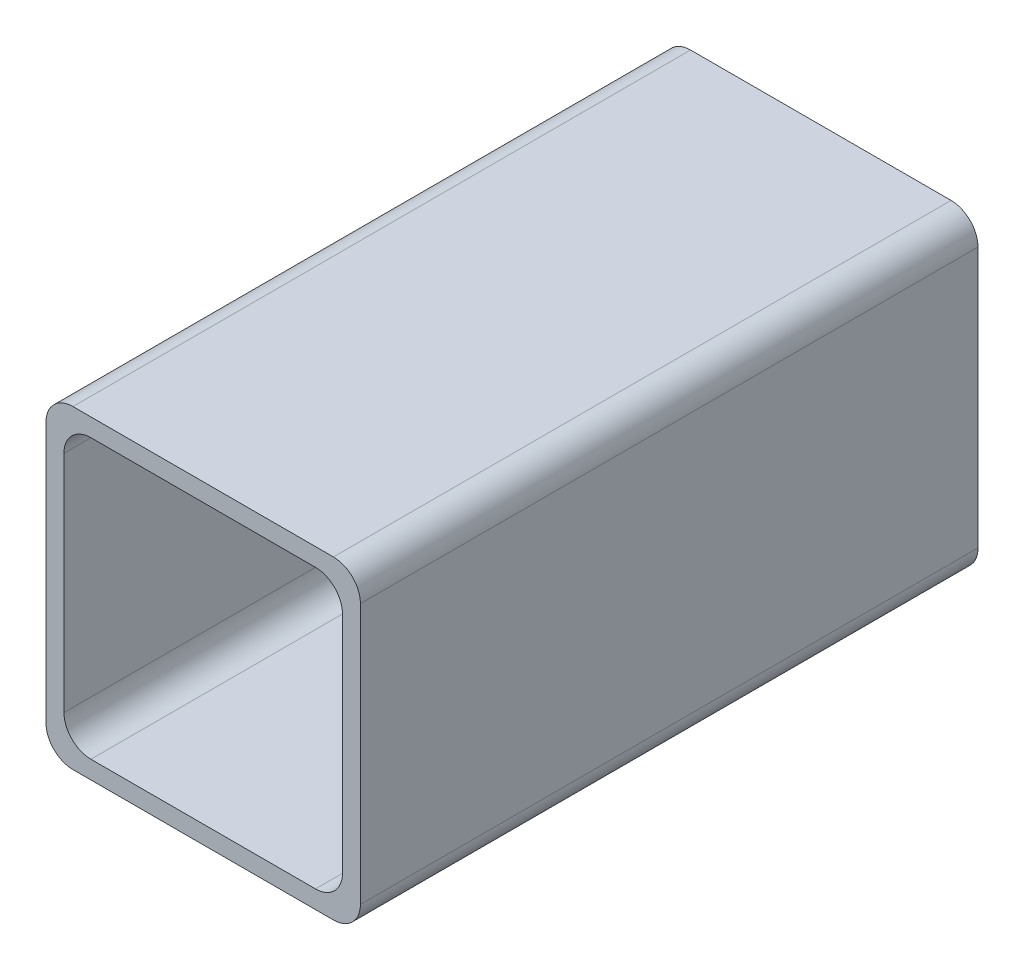
from build123d import *

# Parameters (mm, degrees)
EXTRUDE_1_DEPTH = 68.75


with BuildPart() as part:
    # Эскиз1 → Бобышка-Вытянуть1 (new body)
    with BuildSketch(Plane.XY):
        with BuildLine():
            Line((14.5, 17.5), (-14.5, 17.5))
            ThreePointArc((-14.5, 17.5), (-16.621320344, 16.621320344), (-17.5, 14.5))
            Line((-17.5, 14.5), (-17.5, -14.5))
            ThreePointArc((-17.5, -14.5), (-16.621320344, -16.621320344), (-14.5, -17.5))
            Line((-14.5, -17.5), (14.5, -17.5))
            ThreePointArc((14.5, -17.5), (16.621320344, -16.621320344), (17.5, -14.5))
            Line((17.5, -14.5), (17.5, 14.5))
            ThreePointArc((17.5, 14.5), (16.621320344, 16.621320344), (14.5, 17.5))
        make_face()
        with BuildLine():
            Line((-15.5, -12.5), (-15.5, 12.5))
            ThreePointArc((-15.5, 12.5), (-14.621320344, 14.621320344), (-12.5, 15.5))
            Line((-12.5, 15.5), (12.5, 15.5))
            ThreePointArc((12.5, 15.5), (14.621320344, 14.621320344), (15.5, 12.5))
            Line((15.5, 12.5), (15.5, -12.5))
            ThreePointArc((15.5, -12.5), (14.621320344, -14.621320344), (12.5, -15.5))
            Line((12.5, -15.5), (-12.5, -15.5))
            ThreePointArc((-12.5, -15.5), (-14.621320344, -14.621320344), (-15.5, -12.5))
        make_face(mode=Mode.SUBTRACT)
    extrude(amount=EXTRUDE_1_DEPTH)


solid = part.part
